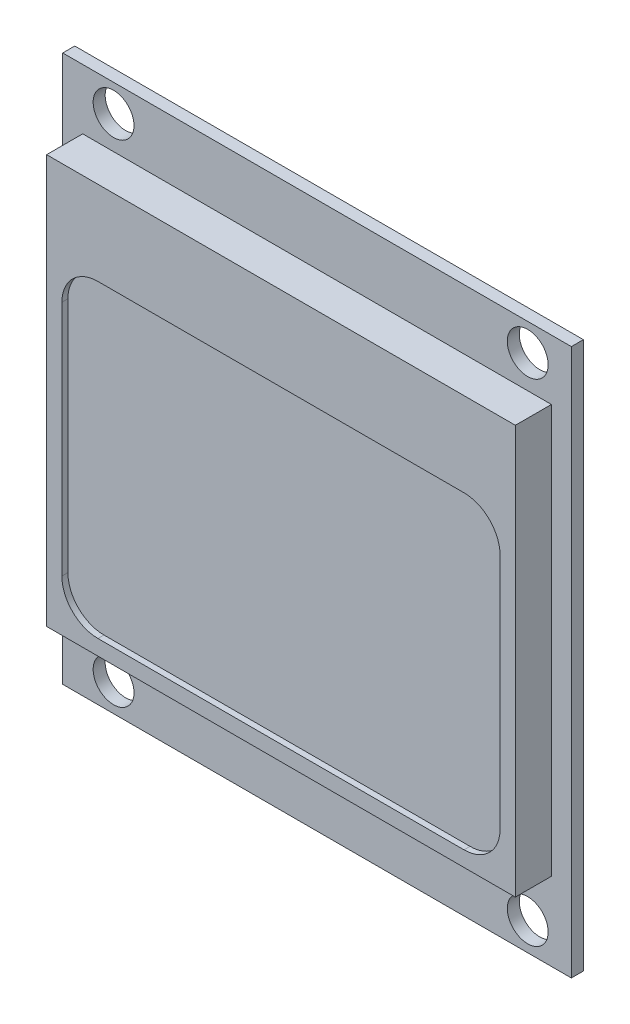
from build123d import *

# Parameters (mm, degrees)
SKETCH_1_W          = 20.32
SKETCH_1_H          = 2.54
EXTRUDE_1_DEPTH     = 11
SKETCH_2_W          = 42.32
SKETCH_2_H          = 45.5
SKETCH_2_R          = 1.7
EXTRUDE_2_DEPTH     = 1
SKETCH_3_W          = 39
SKETCH_3_H          = 34
EXTRUDE_3_DEPTH     = 3
CUT_EXTRUDE_1_DEPTH = 0.5


with BuildPart() as part:
    # 草图1 → 凸台-拉伸1 (new body)
    with BuildSketch(Plane.XY):
        with Locations((34.416985014, 23.365786132)):
            Rectangle(SKETCH_1_W, SKETCH_1_H)
    extrude(amount=EXTRUDE_1_DEPTH)

    # 草图2 → 凸台-拉伸2 (add)
    with BuildSketch(Plane.XY.offset(11)):
        with Locations((34.416985014, 42.762700025)):
            Rectangle(SKETCH_2_W, SKETCH_2_H)
        with Locations((17.486918974, 22.360680721)):
            Circle(SKETCH_2_R, mode=Mode.SUBTRACT)
        with Locations((51.946913894, 22.360680721)):
            Circle(SKETCH_2_R, mode=Mode.SUBTRACT)
        with Locations((17.486918974, 63.235712471)):
            Circle(SKETCH_2_R, mode=Mode.SUBTRACT)
        with Locations((51.946913894, 63.235712471)):
            Circle(SKETCH_2_R, mode=Mode.SUBTRACT)
    extrude(amount=EXTRUDE_2_DEPTH)

    # 草图3 → 凸台-拉伸3 (add)
    with BuildSketch(Plane.XY.offset(12)):
        with Locations((34.416985014, 43.512700025)):
            Rectangle(SKETCH_3_W, SKETCH_3_H)
    extrude(amount=EXTRUDE_3_DEPTH)

    # 草图4 → 切除-拉伸1 (cut)
    with BuildSketch(Plane.XY.offset(15)):
        with BuildLine():
            Line((49.646985014, 27.782700025), (19.186985014, 27.782700025))
            ThreePointArc((19.186985014, 27.782700025), (17.06566467, 28.661379682), (16.186985014, 30.782700025))
            Line((16.186985014, 30.782700025), (16.186985014, 50.512700025))
            ThreePointArc((16.186985014, 50.512700025), (17.06566467, 52.634020369), (19.186985014, 53.512700025))
            Line((19.186985014, 53.512700025), (49.646985014, 53.512700025))
            ThreePointArc((49.646985014, 53.512700025), (51.768305358, 52.634020369), (52.646985014, 50.512700025))
            Line((52.646985014, 50.512700025), (52.646985014, 30.782700025))
            ThreePointArc((52.646985014, 30.782700025), (51.768305358, 28.661379682), (49.646985014, 27.782700025))
        make_face()
    extrude(amount=-CUT_EXTRUDE_1_DEPTH, mode=Mode.SUBTRACT)


solid = part.part
